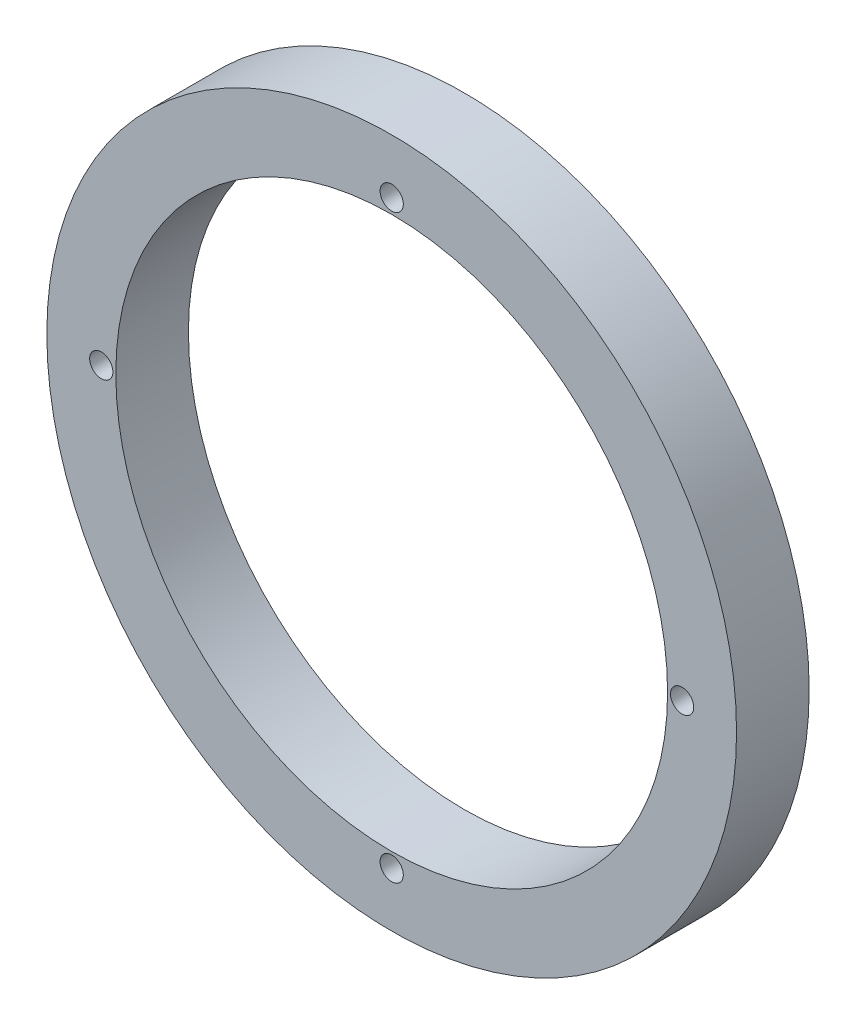
from build123d import *

# Parameters (mm, degrees)
ESQUISSE1_R        = 4.75
ESQUISSE1_R_2      = 3.8
ESQUISSE1_R_3      = 0.16
BOSS_EXTRU_1_DEPTH = 1


with BuildPart() as part:
    # Esquisse1 → Boss.-Extru.1 (new body)
    with BuildSketch(Plane.XY):
        Circle(ESQUISSE1_R)
        Circle(ESQUISSE1_R_2, mode=Mode.SUBTRACT)
        with Locations((0, 4)):
            Circle(ESQUISSE1_R_3, mode=Mode.SUBTRACT)
        with Locations((4, 0)):
            Circle(ESQUISSE1_R_3, mode=Mode.SUBTRACT)
        with Locations((0, -4)):
            Circle(ESQUISSE1_R_3, mode=Mode.SUBTRACT)
        with Locations((-4, 0)):
            Circle(ESQUISSE1_R_3, mode=Mode.SUBTRACT)
    extrude(amount=BOSS_EXTRU_1_DEPTH)


solid = part.part
